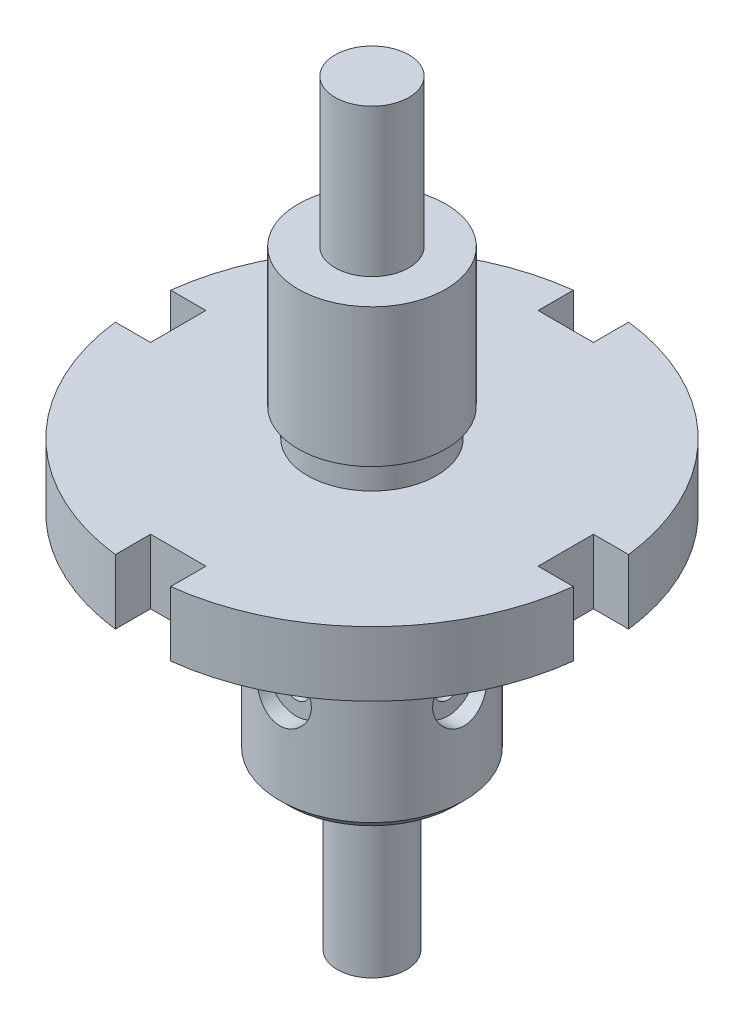
from build123d import *

# Parameters (mm, degrees)
CUT_EXTRUDE1_DEPTH = 14
CIRPATTERN1_COUNT  = 4
CIRPATTERN2_COUNT  = 4
CHAMFER3_SIZE      = 2


with BuildPart() as part:
    # Sketch1 → Revolve1 (revolve)
    with BuildSketch(Plane.XY, mode=Mode.PRIVATE) as revolve1_sk:
        Polygon((7.5, 0), (7.5, 30), (6, 30), (6, 36), (20, 36), (20, 76), (18, 76), (18, 82), (50, 82), (50, 96), (14, 96), (14, 102), (16, 102), (16, 132), (8, 132), (8, 164), (0, 164), (0, 0), align=None)
    revolve(revolve1_sk.sketch.rotate(Axis((0, 0, 0), (0, 1, 0)), 90), axis=Axis((0, 0, 0), (0, 1, 0)))  # turned: the seam where the file's is

    # Sketch2 → Cut-Extrude1 (cut)
    with BuildSketch(Plane(origin=(0, 96, 0), x_dir=(1, 0, 0), z_dir=(0, 1, 0))):
        with BuildLine():
            Line((42, 6), (49.638694584, 6))
            ThreePointArc((49.638694584, 6), (50, 0), (49.638694584, -6))
            Line((49.638694584, -6), (42, -6))
            Line((42, -6), (42, 6))
        make_face()
    cut_extrude1 = extrude(amount=-CUT_EXTRUDE1_DEPTH, mode=Mode.SUBTRACT)

    # CirPattern1: Cut-Extrude1 ×4 about axis
    cirpattern1_axis = Axis((0, 0, 0), (0, 1, 0))
    for i in range(1, CIRPATTERN1_COUNT):
        add(cut_extrude1.rotate(cirpattern1_axis, i * 360 / CIRPATTERN1_COUNT), mode=Mode.SUBTRACT)

    # Sketch6 → CBORE for #12 Binding Head Machine Screw3 (revolve, cut)
    with BuildSketch(Plane(origin=(0, 58, 20), x_dir=(0, -1, 0), z_dir=(1, 0, 0))):
        Polygon((0, 0), (0, 9.739852008), (2.8956, 8), (2.8956, 3.5814), (5.95376, 3.5814), (5.95376, 0), align=None)
    cbore_for_12_binding_head_machine_screw = revolve(axis=Axis((0, 58, 26.35), (0, 0, -1)), mode=Mode.SUBTRACT)

    # CirPattern2: CBORE for #12 Binding Head Machine Screw3 ×4 about axis
    cirpattern2_axis = Axis((0, 0, 0), (0, 1, 0))
    for i in range(1, CIRPATTERN2_COUNT):
        add(cbore_for_12_binding_head_machine_screw.rotate(cirpattern2_axis, i * 360 / CIRPATTERN2_COUNT), mode=Mode.SUBTRACT)

    # Chamfer3
    chamfer3_edges = [part.edges().sort_by_distance(p)[0] for p in [
        (0, 36, 20),
    ]]
    chamfer(chamfer3_edges, length=CHAMFER3_SIZE)


solid = part.part
